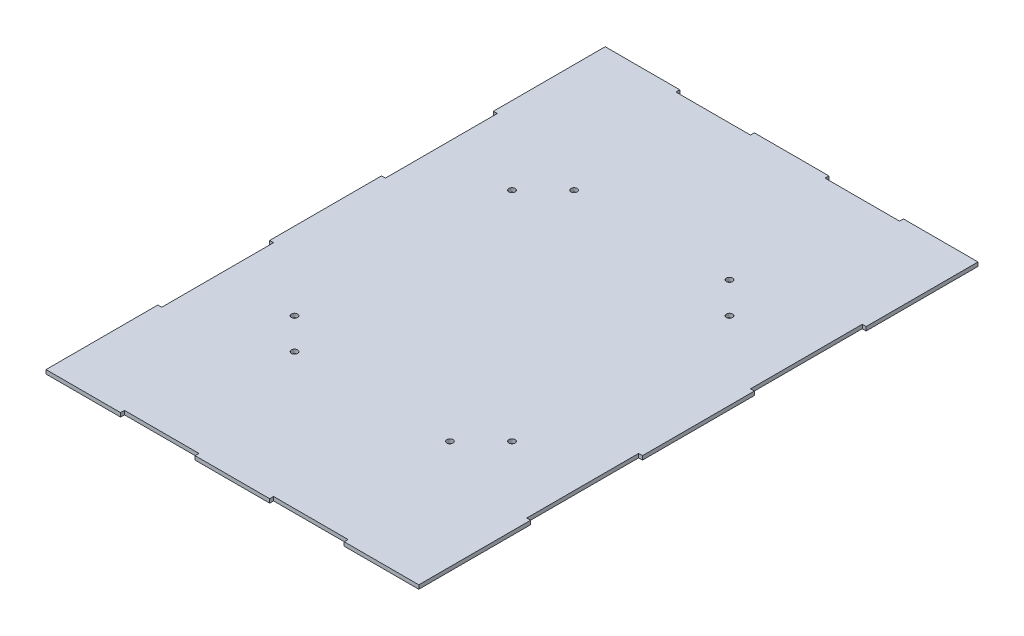
from build123d import *

# Parameters (mm, degrees)
SKETCH1_W           = 304.8
SKETCH1_H           = 457.2
BOSS_EXTRUDE1_DEPTH = 3.175
SKETCH3_R           = 2.54
SKETCH3_W           = 60.96
SKETCH3_H           = 3.175
SKETCH3_W_2         = 3.175
SKETCH3_H_2         = 91.44
CUT_EXTRUDE1_DEPTH  = 6.35


with BuildPart() as part:
    # Sketch1 → Boss-Extrude1 (new body)
    with BuildSketch(Plane(origin=(0, 0, 0), x_dir=(1, 0, 0), z_dir=(0, 1, 0))):
        Rectangle(SKETCH1_W, SKETCH1_H)
    extrude(amount=BOSS_EXTRUDE1_DEPTH)

    # Sketch3 → Cut-Extrude1 (cut)
    with BuildSketch(Plane(origin=(0, 3.175, 0), x_dir=(1, 0, 0), z_dir=(0, 1, 0))):
        with Locations(Location((-63.5, -114.3, 0), (0, 0, 270))):  # turned: the seam where the file's is
            Circle(SKETCH3_R)
        with Locations(Location((-88.9, -88.9, 0), (0, 0, 270))):  # turned: the seam where the file's is
            Circle(SKETCH3_R)
        with Locations(Location((88.9, -88.9, 0), (0, 0, 270))):  # turned: the seam where the file's is
            Circle(SKETCH3_R)
        with Locations(Location((63.5, -114.3, 0), (0, 0, 270))):  # turned: the seam where the file's is
            Circle(SKETCH3_R)
        with Locations(Location((63.5, 114.3, 0), (0, 0, 270))):  # turned: the seam where the file's is
            Circle(SKETCH3_R)
        with Locations(Location((88.9, 88.9, 0), (0, 0, 270))):  # turned: the seam where the file's is
            Circle(SKETCH3_R)
        with Locations(Location((-88.9, 88.9, 0), (0, 0, 270))):  # turned: the seam where the file's is
            Circle(SKETCH3_R)
        with Locations(Location((-63.5, 114.3, 0), (0, 0, 270))):  # turned: the seam where the file's is
            Circle(SKETCH3_R)
        with Locations((-60.96, 227.0125)):
            Rectangle(SKETCH3_W, SKETCH3_H)
        with Locations((-60.96, -227.0125)):
            Rectangle(SKETCH3_W, SKETCH3_H)
        with Locations((60.96, -227.0125)):
            Rectangle(SKETCH3_W, SKETCH3_H)
        with Locations((60.96, 227.0125)):
            Rectangle(SKETCH3_W, SKETCH3_H)
        with Locations((150.8125, 91.44)):
            Rectangle(SKETCH3_W_2, SKETCH3_H_2)
        with Locations((150.8125, -91.44)):
            Rectangle(SKETCH3_W_2, SKETCH3_H_2)
        with Locations((-150.8125, 91.44)):
            Rectangle(SKETCH3_W_2, SKETCH3_H_2)
        with Locations((-150.8125, -91.44)):
            Rectangle(SKETCH3_W_2, SKETCH3_H_2)
    extrude(amount=-CUT_EXTRUDE1_DEPTH, mode=Mode.SUBTRACT)


solid = part.part
